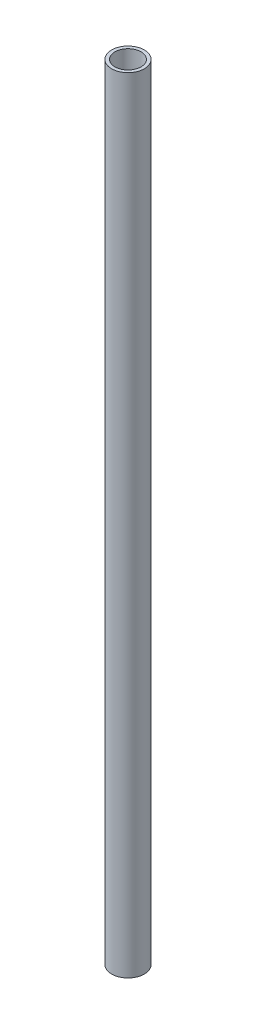
from build123d import *

# Parameters (mm, degrees)
SKETCH1_R           = 5
SKETCH1_R_2         = 4
BOSS_EXTRUDE1_DEPTH = 120


with BuildPart() as part:
    # Sketch1 → Boss-Extrude1 (new body, symmetric)
    with BuildSketch(Plane(origin=(0, 0, 0), x_dir=(1, 0, 0), z_dir=(0, 1, 0))):
        Circle(SKETCH1_R)
        Circle(SKETCH1_R_2, mode=Mode.SUBTRACT)
    extrude(amount=BOSS_EXTRUDE1_DEPTH, both=True)


solid = part.part
